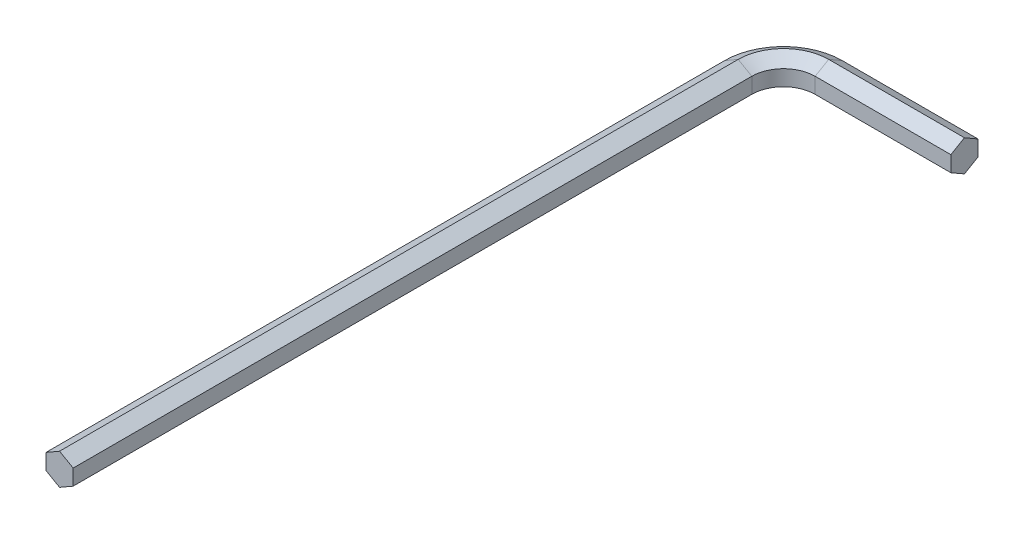
from build123d import *


with BuildPart() as part:
    # Sweep1: sweep along a path in Sketch2
    with BuildLine(Plane(origin=(0, 0, 0), x_dir=(1, 0, 0), z_dir=(0, 1, 0))) as sweep1_path:
        Line((0, 0), (0, 75))
        ThreePointArc((0, 75), (1.464466094, 78.535533906), (5, 80))
        Line((5, 80), (20, 80))
    # Sketch1 → Sweep1 (sweep)
    with BuildSketch(Plane.XY):
        Polygon((-1.5, 0.866025404), (-1.5, -0.866025404), (0, -1.732050808), (1.5, -0.866025404), (1.5, 0.866025404), (0, 1.732050808), align=None)
    sweep(path=sweep1_path.line)


solid = part.part
